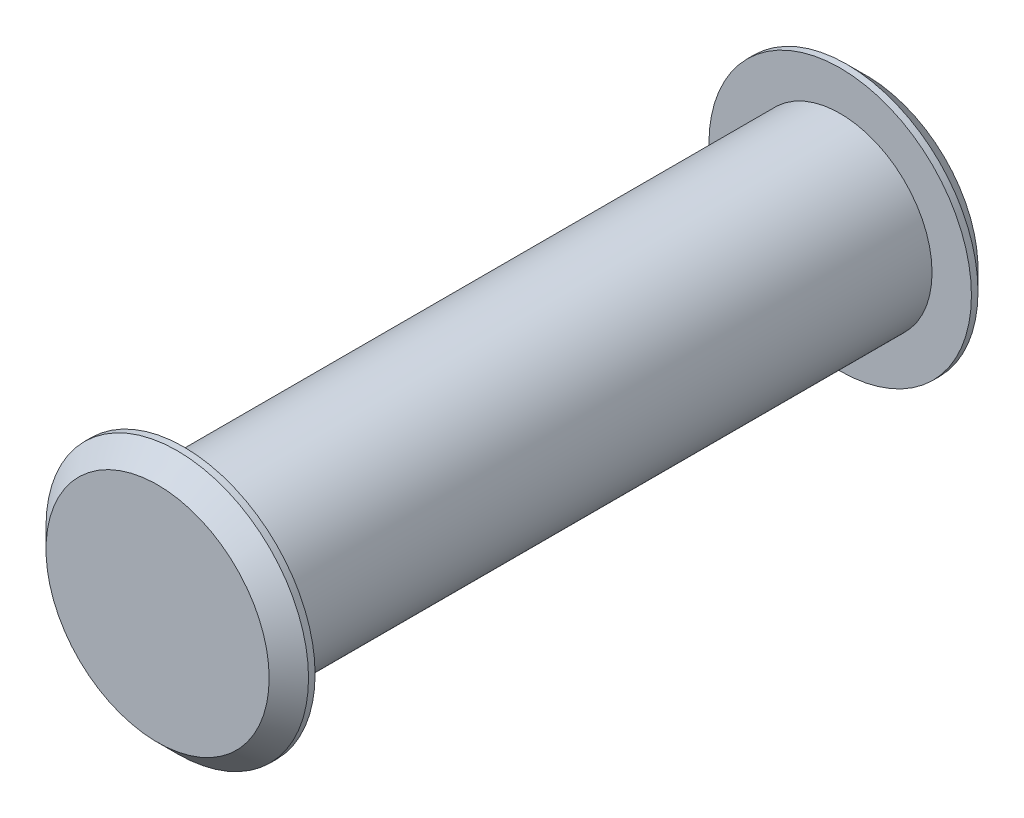
from build123d import *

# Parameters (mm, degrees)
SKETCH1_R           = 3.5
BOSS_EXTRUDE1_DEPTH = 12.5
SKETCH2_R           = 5
BOSS_EXTRUDE2_DEPTH = 1
CHAMFER1_SIZE       = 0.75


with BuildPart() as part:
    # Sketch1 → Boss-Extrude1 (new body, symmetric)
    with BuildSketch(Plane.XY):
        Circle(SKETCH1_R)
    extrude(amount=BOSS_EXTRUDE1_DEPTH, both=True)

    # Sketch2 → Boss-Extrude2 (add)
    with BuildSketch(Plane.XY.offset(12.5)):
        Circle(SKETCH2_R)
    boss_extrude2 = extrude(amount=BOSS_EXTRUDE2_DEPTH)

    # Mirror1: Boss-Extrude2 across plane
    add(boss_extrude2.mirror(Plane.XY))

    # Chamfer1
    chamfer1_edges = [part.edges().sort_by_distance(p)[0] for p in [
        (-5, 0, 13.5),
        (-5, 0, -13.5),
    ]]
    chamfer(chamfer1_edges, length=CHAMFER1_SIZE)


solid = part.part
